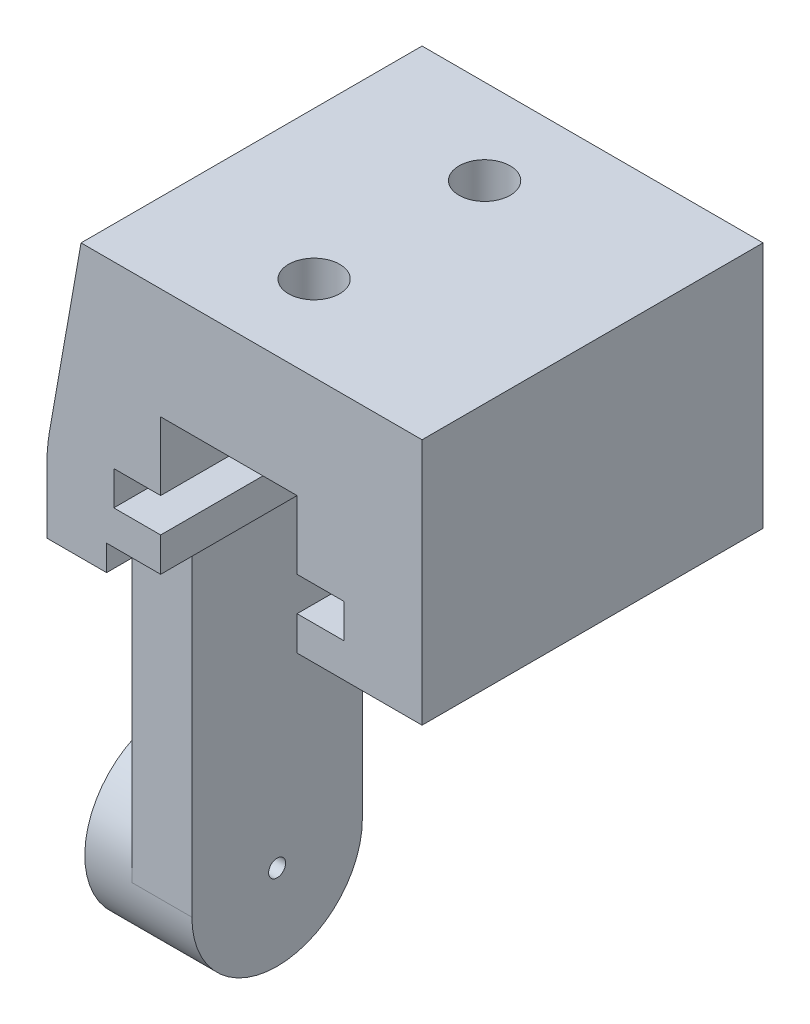
from build123d import *

# Parameters (mm, degrees)
SKETCH1_W           = 22
SKETCH1_H           = 16
BOSS_EXTRUDE1_DEPTH = 20
CHAMFER1_SIZE       = 2
CHAMFER1_SIZE2      = 11.342563639
CUT_EXTRUDE1_DEPTH  = 20
FILLET1_R           = 10
SKETCH3_W           = 3.5
SKETCH3_H           = 10
BOSS_EXTRUDE2_DEPTH = 20
FILLET2_R           = 1
BOSS_EXTRUDE3_DEPTH = 3.5
SKETCH8_R           = 0.5
CUT_EXTRUDE2_DEPTH  = 3.5
SKETCH9_R           = 1.5
CUT_EXTRUDE3_DEPTH  = 6.5
SKETCH10_R          = 5
SKETCH10_R_2        = 0.5
BOSS_EXTRUDE4_DEPTH = 2.78


with BuildPart() as part:
    # Sketch1 → Boss-Extrude1 (new body)
    with BuildSketch(Plane.XY):
        with Locations((11, -8)):
            Rectangle(SKETCH1_W, SKETCH1_H)
    extrude(amount=BOSS_EXTRUDE1_DEPTH)

    # Chamfer1
    chamfer1_edges = [part.edges().sort_by_distance(p)[0] for p in [
        (0, 0, 10),
    ]]
    chamfer1_side = [part.faces().sort_by_distance(p)[0] for p in [
        (11, 0, 10),
    ]]
    chamfer(chamfer1_edges, length=CHAMFER1_SIZE, length2=CHAMFER1_SIZE2, reference=chamfer1_side[0])

    # Sketch2 → Cut-Extrude1 (cut)
    with BuildSketch(Plane.XY.offset(20)):
        Polygon((3.5, -16), (3.5, -14.5), (6.67, -14.5), (6.67, -12.5), (3.92, -12.5), (3.92, -10.5), (6.67, -10.5), (6.67, -6.5), (14.67, -6.5), (14.67, -10.5), (17.42, -10.5), (17.42, -12.5), (14.67, -12.5), (14.67, -14.5), (22, -14.5), (22, -16), align=None)
    extrude(amount=-CUT_EXTRUDE1_DEPTH, mode=Mode.SUBTRACT)

    # Fillet1
    fillet1_edges = [part.edges().sort_by_distance(p)[0] for p in [
        (0, -11.342563639, 10),
    ]]
    fillet(fillet1_edges, radius=FILLET1_R)

    # Sketch3 → Boss-Extrude2 (add)
    with BuildSketch(Plane.XZ.offset(16)):
        with Locations((1.75, 10)):
            Rectangle(SKETCH3_W, SKETCH3_H)
    extrude(amount=BOSS_EXTRUDE2_DEPTH)

    # Fillet2
    fillet2_edges = [part.edges().sort_by_distance(p)[0] for p in [
        (1.75, -16, 5),
        (1.75, -16, 15),
    ]]
    fillet(fillet2_edges, radius=FILLET2_R)

    # Sketch7 → Boss-Extrude3 (add)
    with BuildSketch(Plane.ZY):
        with BuildLine():
            Line((15, -36), (5, -36))
            ThreePointArc((5, -36), (10, -41), (15, -36))
        make_face()
    extrude(amount=-BOSS_EXTRUDE3_DEPTH)

    # Sketch8 → Cut-Extrude2 (cut)
    with BuildSketch(Plane.ZY):
        with Locations((10, -36)):
            Circle(SKETCH8_R)
    extrude(amount=-CUT_EXTRUDE2_DEPTH, mode=Mode.SUBTRACT)

    # Sketch9 → Cut-Extrude3 (cut)
    with BuildSketch(Plane.XZ.offset(6.5)):
        with Locations((10.67, 15)):
            Circle(SKETCH9_R)
        with Locations((10.67, 5)):
            Circle(SKETCH9_R)
    extrude(amount=-CUT_EXTRUDE3_DEPTH, mode=Mode.SUBTRACT)

    # Sketch10 → Boss-Extrude4 (add)
    with BuildSketch(Plane.ZY):
        with Locations((10, -36)):
            Circle(SKETCH10_R)
        with Locations((10, -36)):
            Circle(SKETCH10_R_2, mode=Mode.SUBTRACT)
    extrude(amount=BOSS_EXTRUDE4_DEPTH)


solid = part.part
